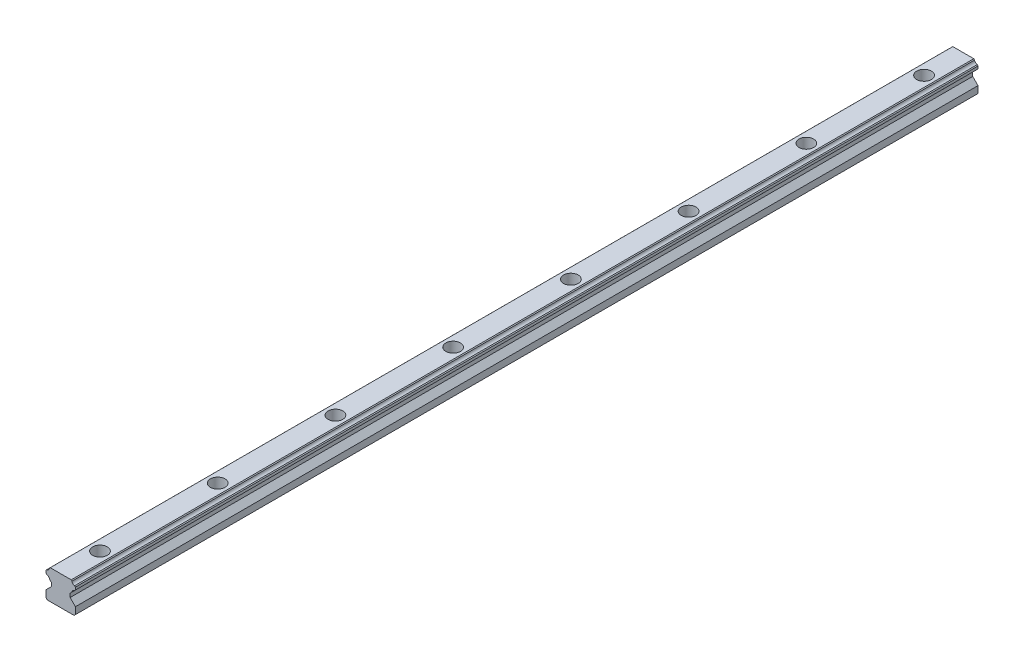
from build123d import *

# Parameters (mm, degrees)
EXTRUDE1_DEPTH  = 460
LPATTERN1_COUNT = 8
LPATTERN1_PITCH = 60


with BuildPart() as part:
    # Sketch1 → Extrude1 (new body)
    with BuildSketch(Plane(origin=(-20, 0, 0), x_dir=(1, 0, 0), z_dir=(0, 0, 1))):
        with BuildLine():
            Line((12.5, 0.69999271), (13.199992786, 0))
            Line((13.199992786, 0), (26.800007214, 0))
            Line((26.800007214, 0), (27.5, 0.69999271))
            Line((27.5, 0.69999271), (27.5, 4.2000246))
            Line((27.5, 4.2000246), (24.8000183, 6.9000063))
            Line((24.8000183, 6.9000063), (24.8000183, 8.8400054))
            Line((24.8000183, 8.8400054), (25.755946813, 9.794179118))
            ThreePointArc((25.755946813, 9.794179118), (26.198484624, 10.690600567), (27.09432569, 11.13431209))
            Line((27.09432569, 11.13431209), (27.5, 11.5399866))
            Line((27.5, 11.5399866), (27.5, 12.8500204))
            Line((27.5, 12.8500204), (27.09432569, 13.268442751))
            ThreePointArc((27.09432569, 13.268442751), (26.202460867, 13.706434947), (25.755946813, 14.594063938))
            Line((25.755946813, 14.594063938), (25.3500197, 15))
            Line((25.3500197, 15), (14.6499803, 15))
            Line((14.6499803, 15), (14.244053187, 14.594063938))
            ThreePointArc((14.244053187, 14.594063938), (13.797539133, 13.706434947), (12.90567431, 13.268442751))
            Line((12.90567431, 13.268442751), (12.5, 12.8500204))
            Line((12.5, 12.8500204), (12.5, 11.5399866))
            Line((12.5, 11.5399866), (12.90567431, 11.13431209))
            ThreePointArc((12.90567431, 11.13431209), (13.801515376, 10.690600567), (14.244053187, 9.794179118))
            Line((14.244053187, 9.794179118), (15.1999817, 8.8400054))
            Line((15.1999817, 8.8400054), (15.1999817, 6.9000063))
            Line((15.1999817, 6.9000063), (12.5, 4.2000246))
            Line((12.5, 4.2000246), (12.5, 0.69999271))
        make_face()
    extrude(amount=-EXTRUDE1_DEPTH)

    # Sketch2 → Cut-Revolve1 (revolve, cut)
    with BuildSketch(Plane(origin=(0, 0, 0), x_dir=(0, 0, -1), z_dir=(1, 0, 0))):
        Polygon((20, 15), (23.75, 15), (23.75, 9.7), (22.25, 9.7), (22.25, 0), (20, 0), align=None)
    cut_revolve1 = revolve(axis=Axis((0, 0, -20), (0, 1, 0)), mode=Mode.SUBTRACT)

    # LPattern1: Cut-Revolve1 ×8
    with Locations(*[(0, 0, -i * LPATTERN1_PITCH) for i in range(1, LPATTERN1_COUNT)]):
        add(cut_revolve1, mode=Mode.SUBTRACT)


solid = part.part
